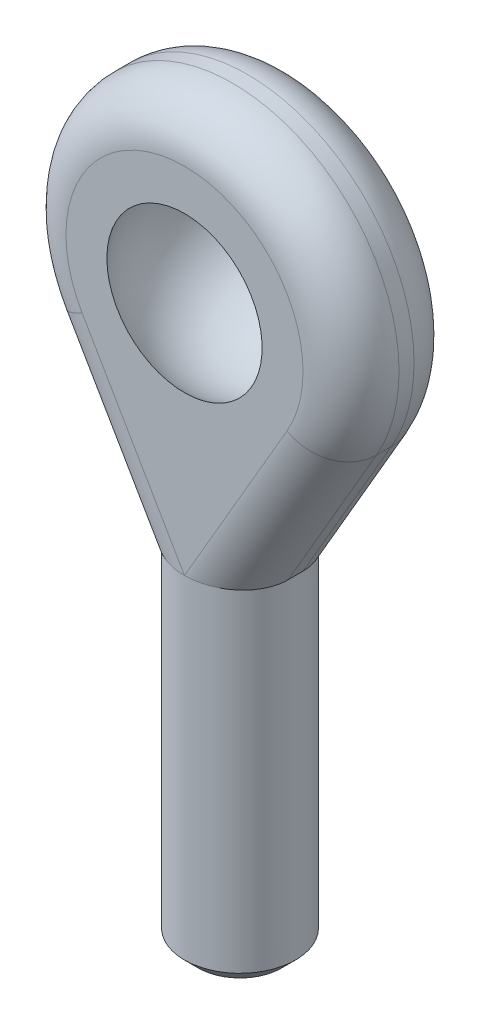
from build123d import *

# Parameters (mm, degrees)
SKETCH1_R           = 4
BOSS_EXTRUDE1_DEPTH = 12.5
BOSS_EXTRUDE6_DEPTH = 4
CHAMFER1_SIZE       = 1
FILLET6_R           = 3.4584


with BuildPart() as part:
    # Sketch1 → Boss-Extrude1 (new body, symmetric)
    with BuildSketch(Plane(origin=(0, 0, 0), x_dir=(1, 0, 0), z_dir=(0, 1, 0))):
        Circle(SKETCH1_R)
    extrude(amount=BOSS_EXTRUDE1_DEPTH, both=True)

    # Sketch10 → Boss-Extrude6 (add, symmetric)
    with BuildSketch(Plane.XY):
        with BuildLine():
            Line((-10.37531088, 23.470661383), (-4, 12.5))
            Line((-4, 12.5), (4, 12.5))
            Line((4, 12.5), (10.37531088, 23.470661383))
            ThreePointArc((10.37531088, 23.470661383), (0, 41.5), (-10.37531088, 23.470661383))
        make_face()
    extrude(amount=BOSS_EXTRUDE6_DEPTH, both=True)

    # Chamfer1
    chamfer1_edges = [part.edges().sort_by_distance(p)[0] for p in [
        (-4, -12.5, 0),
    ]]
    chamfer(chamfer1_edges, length=CHAMFER1_SIZE)

    # Sketch11 → Cut-Revolve1 (revolve, cut)
    with BuildSketch(Plane(origin=(0, 0, 0), x_dir=(0, 0, -1), z_dir=(1, 0, 0))):
        with BuildLine():
            Line((-4.5, 29.5), (4.5, 29.5))
            Line((4.5, 29.5), (4.5, 34.7))
            ThreePointArc((4.5, 34.7), (0, 36.376772499), (-4.5, 34.7))
            Line((-4.5, 34.7), (-4.5, 29.5))
        make_face()
    revolve(axis=Axis((0, 29.5, 4.5), (0, 0, -1)), mode=Mode.SUBTRACT)

    # Fillet6
    fillet6_edges = [part.edges().sort_by_distance(p)[0] for p in [
        (-7.18765544, 17.985330692, 4),
        (0, 41.5, 4),
        (7.18765544, 17.985330692, 4),
        (7.18765544, 17.985330692, -4),
        (0, 41.5, -4),
        (-7.18765544, 17.985330692, -4),
    ]]
    fillet(fillet6_edges, radius=FILLET6_R)


solid = part.part
